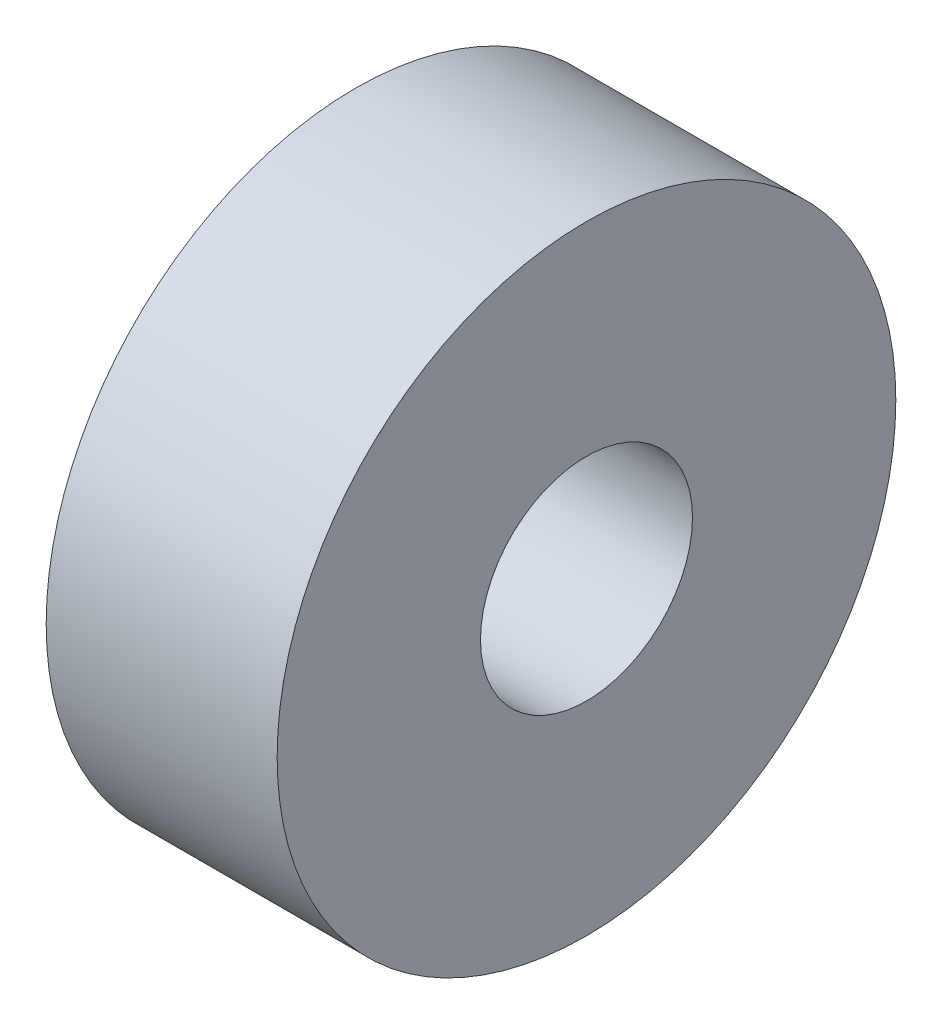
from build123d import *

# Parameters (mm, degrees)
SKETCH2_R           = 9.525
SKETCH2_R_2         = 3.2639
BOSS_EXTRUDE1_DEPTH = 7.112


with BuildPart() as part:
    # Sketch2 → Boss-Extrude1 (new body)
    with BuildSketch(Plane(origin=(0, 0, 0), x_dir=(0, 0, -1), z_dir=(1, 0, 0))):
        Circle(SKETCH2_R)
        Circle(SKETCH2_R_2, mode=Mode.SUBTRACT)
    extrude(amount=BOSS_EXTRUDE1_DEPTH)


solid = part.part
